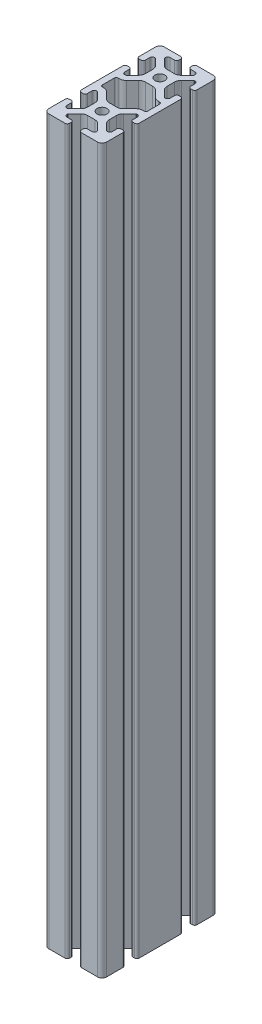
from build123d import *

# Parameters (mm, degrees)
SKETCH1_R                    = 3.4
F_30_30_3060_PROFILE_1_DEPTH = 500


with BuildPart() as part:
    # Sketch1 → 30 30-3060 PROFILE(1) (new body)
    with BuildSketch(Plane(origin=(0, 0, 0), x_dir=(1, 0, 0), z_dir=(0, 1, 0))):
        with BuildLine():
            Line((20, 5.63), (20, 34.37))
            ThreePointArc((20, 34.37), (19.540157646, 35.480157646), (18.43, 35.94))
            Line((18.43, 35.94), (17.252, 35.94))
            ThreePointArc((17.252, 35.94), (16.141842354, 35.480157646), (15.682, 34.37))
            Line((15.682, 34.37), (15.682, 31.285))
            ThreePointArc((15.682, 31.285), (15.222157646, 30.174842354), (14.112, 29.715))
            Line((14.112, 29.715), (13.654503602, 29.715))
            ThreePointArc((13.654503602, 29.715), (13.363664194, 29.772851555), (13.117102448, 29.937598846))
            Line((13.117102448, 29.937598846), (8.919842789, 34.134858505))
            ThreePointArc((8.919842789, 34.134858505), (7.890172221, 35.675869412), (7.5286, 37.493615716))
            Line((7.5286, 37.493615716), (7.5286, 42.506384284))
            ThreePointArc((7.5286, 42.506384284), (7.890172221, 44.324130588), (8.919842789, 45.865141495))
            Line((8.919842789, 45.865141495), (13.117102448, 50.062401154))
            ThreePointArc((13.117102448, 50.062401154), (13.363664194, 50.227148445), (13.654503602, 50.285))
            Line((13.654503602, 50.285), (14.112, 50.285))
            ThreePointArc((14.112, 50.285), (15.222157646, 49.825157646), (15.682, 48.715))
            Line((15.682, 48.715), (15.682, 45.63))
            ThreePointArc((15.682, 45.63), (16.141842354, 44.519842354), (17.252, 44.06))
            Line((17.252, 44.06), (18.43, 44.06))
            ThreePointArc((18.43, 44.06), (19.540157646, 44.519842354), (20, 45.63))
            Line((20, 45.63), (20, 56.83))
            ThreePointArc((20, 56.83), (19.071528496, 59.071528496), (16.83, 60))
            Line((16.83, 60), (5.63, 60))
            ThreePointArc((5.63, 60), (4.519842354, 59.540157646), (4.06, 58.43))
            Line((4.06, 58.43), (4.06, 57.252))
            ThreePointArc((4.06, 57.252), (4.519842354, 56.141842354), (5.63, 55.682))
            Line((5.63, 55.682), (8.715, 55.682))
            ThreePointArc((8.715, 55.682), (9.825157646, 55.222157646), (10.285, 54.112))
            Line((10.285, 54.112), (10.285, 53.654503602))
            ThreePointArc((10.285, 53.654503602), (10.227148445, 53.363664194), (10.062401154, 53.117102448))
            Line((10.062401154, 53.117102448), (5.865141495, 48.919842789))
            ThreePointArc((5.865141495, 48.919842789), (4.324130588, 47.890172221), (2.506384284, 47.5286))
            Line((2.506384284, 47.5286), (-2.506384284, 47.5286))
            ThreePointArc((-2.506384284, 47.5286), (-4.324130588, 47.890172221), (-5.865141495, 48.919842789))
            Line((-5.865141495, 48.919842789), (-10.062401154, 53.117102448))
            ThreePointArc((-10.062401154, 53.117102448), (-10.227148445, 53.363664194), (-10.285, 53.654503602))
            Line((-10.285, 53.654503602), (-10.285, 54.112))
            ThreePointArc((-10.285, 54.112), (-9.825157646, 55.222157646), (-8.715, 55.682))
            Line((-8.715, 55.682), (-5.63, 55.682))
            ThreePointArc((-5.63, 55.682), (-4.519842354, 56.141842354), (-4.06, 57.252))
            Line((-4.06, 57.252), (-4.06, 58.43))
            ThreePointArc((-4.06, 58.43), (-4.519842354, 59.540157646), (-5.63, 60))
            Line((-5.63, 60), (-16.83, 60))
            ThreePointArc((-16.83, 60), (-19.071528496, 59.071528496), (-20, 56.83))
            Line((-20, 56.83), (-20, 45.63))
            ThreePointArc((-20, 45.63), (-19.540157646, 44.519842354), (-18.43, 44.06))
            Line((-18.43, 44.06), (-17.252, 44.06))
            ThreePointArc((-17.252, 44.06), (-16.141842354, 44.519842354), (-15.682, 45.63))
            Line((-15.682, 45.63), (-15.682, 48.715))
            ThreePointArc((-15.682, 48.715), (-15.222157646, 49.825157646), (-14.112, 50.285))
            Line((-14.112, 50.285), (-13.654503602, 50.285))
            ThreePointArc((-13.654503602, 50.285), (-13.363664194, 50.227148445), (-13.117102448, 50.062401154))
            Line((-13.117102448, 50.062401154), (-8.919842789, 45.865141495))
            ThreePointArc((-8.919842789, 45.865141495), (-7.890172221, 44.324130588), (-7.5286, 42.506384284))
            Line((-7.5286, 42.506384284), (-7.5286, 37.493615716))
            ThreePointArc((-7.5286, 37.493615716), (-7.890172221, 35.675869412), (-8.919842789, 34.134858505))
            Line((-8.919842789, 34.134858505), (-13.117102448, 29.937598846))
            ThreePointArc((-13.117102448, 29.937598846), (-13.363664194, 29.772851555), (-13.654503602, 29.715))
            Line((-13.654503602, 29.715), (-14.112, 29.715))
            ThreePointArc((-14.112, 29.715), (-15.222157646, 30.174842354), (-15.682, 31.285))
            Line((-15.682, 31.285), (-15.682, 34.37))
            ThreePointArc((-15.682, 34.37), (-16.141842354, 35.480157646), (-17.252, 35.94))
            Line((-17.252, 35.94), (-18.43, 35.94))
            ThreePointArc((-18.43, 35.94), (-19.540157646, 35.480157646), (-20, 34.37))
            Line((-20, 34.37), (-20, 5.63))
            ThreePointArc((-20, 5.63), (-19.540157646, 4.519842354), (-18.43, 4.06))
            Line((-18.43, 4.06), (-17.252, 4.06))
            ThreePointArc((-17.252, 4.06), (-16.141842354, 4.519842354), (-15.682, 5.63))
            Line((-15.682, 5.63), (-15.682, 8.715))
            ThreePointArc((-15.682, 8.715), (-15.222157646, 9.825157646), (-14.112, 10.285))
            Line((-14.112, 10.285), (-13.654503602, 10.285))
            ThreePointArc((-13.654503602, 10.285), (-13.363664194, 10.227148445), (-13.117102448, 10.062401154))
            Line((-13.117102448, 10.062401154), (-8.919842789, 5.865141495))
            ThreePointArc((-8.919842789, 5.865141495), (-7.890172221, 4.324130588), (-7.5286, 2.506384284))
            Line((-7.5286, 2.506384284), (-7.5286, -2.506384284))
            ThreePointArc((-7.5286, -2.506384284), (-7.890172221, -4.324130588), (-8.919842789, -5.865141495))
            Line((-8.919842789, -5.865141495), (-13.117102448, -10.062401154))
            ThreePointArc((-13.117102448, -10.062401154), (-13.363664194, -10.227148445), (-13.654503602, -10.285))
            Line((-13.654503602, -10.285), (-14.112, -10.285))
            ThreePointArc((-14.112, -10.285), (-15.222157646, -9.825157646), (-15.682, -8.715))
            Line((-15.682, -8.715), (-15.682, -5.63))
            ThreePointArc((-15.682, -5.63), (-16.141842354, -4.519842354), (-17.252, -4.06))
            Line((-17.252, -4.06), (-18.43, -4.06))
            ThreePointArc((-18.43, -4.06), (-19.540157646, -4.519842354), (-20, -5.63))
            Line((-20, -5.63), (-20, -16.83))
            ThreePointArc((-20, -16.83), (-19.071528496, -19.071528496), (-16.83, -20))
            Line((-16.83, -20), (-5.63, -20))
            ThreePointArc((-5.63, -20), (-4.519842354, -19.540157646), (-4.06, -18.43))
            Line((-4.06, -18.43), (-4.06, -17.252))
            ThreePointArc((-4.06, -17.252), (-4.519842354, -16.141842354), (-5.63, -15.682))
            Line((-5.63, -15.682), (-8.715, -15.682))
            ThreePointArc((-8.715, -15.682), (-9.825157646, -15.222157646), (-10.285, -14.112))
            Line((-10.285, -14.112), (-10.285, -13.654503602))
            ThreePointArc((-10.285, -13.654503602), (-10.227148445, -13.363664194), (-10.062401154, -13.117102448))
            Line((-10.062401154, -13.117102448), (-5.865141495, -8.919842789))
            ThreePointArc((-5.865141495, -8.919842789), (-4.324130588, -7.890172221), (-2.506384284, -7.5286))
            Line((-2.506384284, -7.5286), (2.506384284, -7.5286))
            ThreePointArc((2.506384284, -7.5286), (4.324130588, -7.890172221), (5.865141495, -8.919842789))
            Line((5.865141495, -8.919842789), (10.062401154, -13.117102448))
            ThreePointArc((10.062401154, -13.117102448), (10.227148445, -13.363664194), (10.285, -13.654503602))
            Line((10.285, -13.654503602), (10.285, -14.112))
            ThreePointArc((10.285, -14.112), (9.825157646, -15.222157646), (8.715, -15.682))
            Line((8.715, -15.682), (5.63, -15.682))
            ThreePointArc((5.63, -15.682), (4.519842354, -16.141842354), (4.06, -17.252))
            Line((4.06, -17.252), (4.06, -18.43))
            ThreePointArc((4.06, -18.43), (4.519842354, -19.540157646), (5.63, -20))
            Line((5.63, -20), (16.83, -20))
            ThreePointArc((16.83, -20), (19.071528496, -19.071528496), (20, -16.83))
            Line((20, -16.83), (20, -5.63))
            ThreePointArc((20, -5.63), (19.540157646, -4.519842354), (18.43, -4.06))
            Line((18.43, -4.06), (17.252, -4.06))
            ThreePointArc((17.252, -4.06), (16.141842354, -4.519842354), (15.682, -5.63))
            Line((15.682, -5.63), (15.682, -8.715))
            ThreePointArc((15.682, -8.715), (15.222157646, -9.825157646), (14.112, -10.285))
            Line((14.112, -10.285), (13.654503602, -10.285))
            ThreePointArc((13.654503602, -10.285), (13.363664194, -10.227148445), (13.117102448, -10.062401154))
            Line((13.117102448, -10.062401154), (8.919842789, -5.865141495))
            ThreePointArc((8.919842789, -5.865141495), (7.890172221, -4.324130588), (7.5286, -2.506384284))
            Line((7.5286, -2.506384284), (7.5286, 2.506384284))
            ThreePointArc((7.5286, 2.506384284), (7.890172221, 4.324130588), (8.919842789, 5.865141495))
            Line((8.919842789, 5.865141495), (13.117102448, 10.062401154))
            ThreePointArc((13.117102448, 10.062401154), (13.363664194, 10.227148445), (13.654503602, 10.285))
            Line((13.654503602, 10.285), (14.112, 10.285))
            ThreePointArc((14.112, 10.285), (15.222157646, 9.825157646), (15.682, 8.715))
            Line((15.682, 8.715), (15.682, 5.63))
            ThreePointArc((15.682, 5.63), (16.141842354, 4.519842354), (17.252, 4.06))
            Line((17.252, 4.06), (18.43, 4.06))
            ThreePointArc((18.43, 4.06), (19.540157646, 4.519842354), (20, 5.63))
        make_face()
        Circle(SKETCH1_R, mode=Mode.SUBTRACT)
        with Locations((0, 40)):
            Circle(SKETCH1_R, mode=Mode.SUBTRACT)
        with BuildLine():
            Line((15.68, 24.125), (15.68, 15.875))
            ThreePointArc((15.68, 15.875), (15.308025612, 14.976974388), (14.41, 14.605))
            Line((14.41, 14.605), (13.654503602, 14.605))
            ThreePointArc((13.654503602, 14.605), (11.710471766, 14.218308025), (10.062401154, 13.117102448))
            Line((10.062401154, 13.117102448), (5.865141495, 8.919842789))
            ThreePointArc((5.865141495, 8.919842789), (4.324130588, 7.890172221), (2.506384284, 7.5286))
            Line((2.506384284, 7.5286), (-2.506384284, 7.5286))
            ThreePointArc((-2.506384284, 7.5286), (-4.324130588, 7.890172221), (-5.865141495, 8.919842789))
            Line((-5.865141495, 8.919842789), (-10.062401154, 13.117102448))
            ThreePointArc((-10.062401154, 13.117102448), (-11.710471766, 14.218308025), (-13.654503602, 14.605))
            Line((-13.654503602, 14.605), (-14.41, 14.605))
            ThreePointArc((-14.41, 14.605), (-15.308025612, 14.976974388), (-15.68, 15.875))
            Line((-15.68, 15.875), (-15.68, 24.125))
            ThreePointArc((-15.68, 24.125), (-15.308025612, 25.023025612), (-14.41, 25.395))
            Line((-14.41, 25.395), (-13.654503602, 25.395))
            ThreePointArc((-13.654503602, 25.395), (-11.710471766, 25.781691975), (-10.062401154, 26.882897552))
            Line((-10.062401154, 26.882897552), (-5.865141495, 31.080157211))
            ThreePointArc((-5.865141495, 31.080157211), (-4.324130588, 32.109827779), (-2.506384284, 32.4714))
            Line((-2.506384284, 32.4714), (2.506384284, 32.4714))
            ThreePointArc((2.506384284, 32.4714), (4.324130588, 32.109827779), (5.865141495, 31.080157211))
            Line((5.865141495, 31.080157211), (10.062401154, 26.882897552))
            ThreePointArc((10.062401154, 26.882897552), (11.710471766, 25.781691975), (13.654503602, 25.395))
            Line((13.654503602, 25.395), (14.41, 25.395))
            ThreePointArc((14.41, 25.395), (15.308025612, 25.023025612), (15.68, 24.125))
        make_face(mode=Mode.SUBTRACT)
    extrude(amount=F_30_30_3060_PROFILE_1_DEPTH)


solid = part.part
